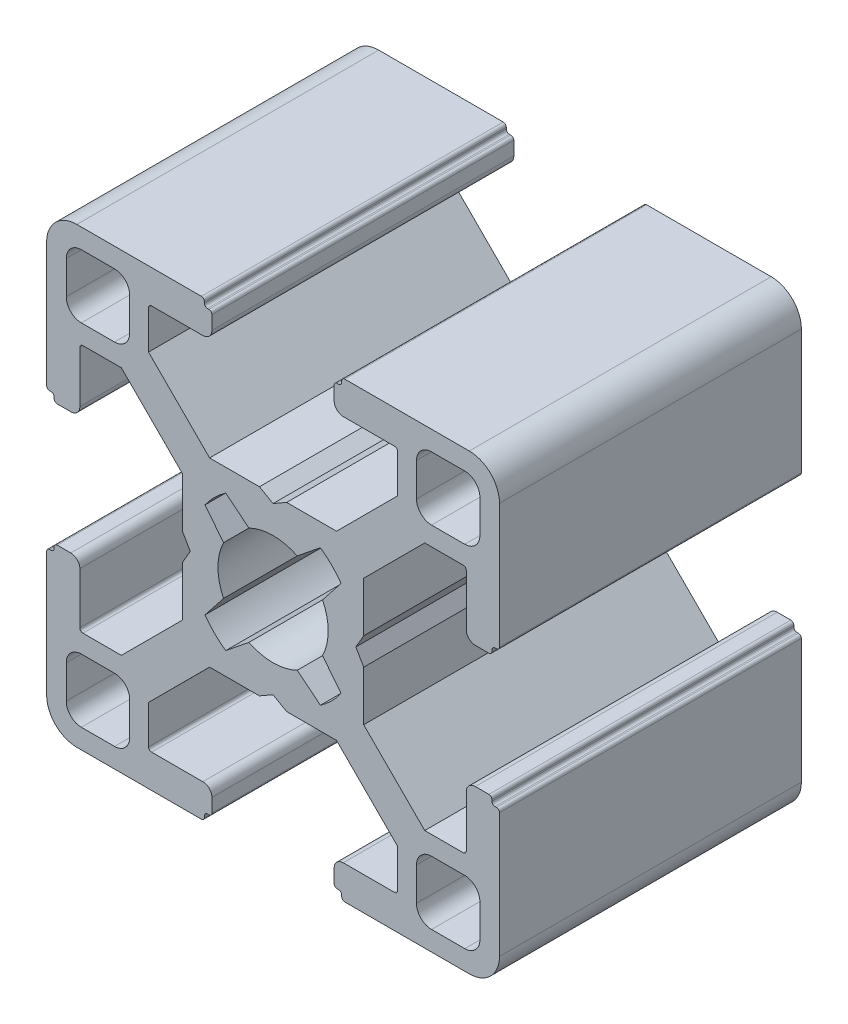
from build123d import *

# Parameters (mm, degrees)
DODANIE_WYCI_GNI_CIE1_DEPTH = 20


with BuildPart() as part:
    # Szkic1 → Dodanie-wyciągnięcie1 (new body)
    with BuildSketch(Plane.XY):
        with BuildLine():
            Line((96.56, 29.575148163), (97.459999946, 29.06))
            Line((97.459999946, 29.06), (100.764466193, 29.06))
            Line((100.764466193, 29.06), (104.810000327, 25.010000763))
            Line((104.810000327, 25.010000763), (104.810000327, 22.460001166))
            ThreePointArc((104.810000327, 22.460001166), (104.751421565, 22.318579525), (104.609999924, 22.260000763))
            Line((104.609999924, 22.260000763), (101.210000197, 22.260000763))
            ThreePointArc((101.210000197, 22.260000763), (100.785735989, 22.084264774), (100.61, 21.660000566))
            Line((100.61, 21.660000566), (100.61, 20.760000374))
            ThreePointArc((100.61, 20.760000374), (100.668578753, 20.618578753), (100.810000374, 20.56))
            Line((100.810000374, 20.56), (100.910000144, 20.56))
            ThreePointArc((100.910000144, 20.56), (101.05142109, 20.501421526), (101.109999564, 20.36000058))
            Line((101.109999564, 20.36000058), (101.109999564, 20.260000381))
            ThreePointArc((101.109999564, 20.260000381), (101.16857832, 20.118578755), (101.309999945, 20.06))
            Line((101.309999945, 20.06), (109.560000346, 20.06))
            ThreePointArc((109.560000346, 20.06), (110.974213664, 20.645786336), (111.56, 22.059999654))
            Line((111.56, 22.059999654), (111.56, 30.310000479))
            ThreePointArc((111.56, 30.310000479), (111.501421273, 30.451422036), (111.359999716, 30.510000763))
            Line((111.359999716, 30.510000763), (111.260000611, 30.510000763))
            ThreePointArc((111.260000611, 30.510000763), (111.118579054, 30.56857949), (111.060000327, 30.710001047))
            Line((111.060000327, 30.710001047), (111.060000327, 30.810000479))
            ThreePointArc((111.060000327, 30.810000479), (111.0014216, 30.951422036), (110.860000043, 31.010000763))
            Line((110.860000043, 31.010000763), (109.95999994, 31.010000763))
            ThreePointArc((109.95999994, 31.010000763), (109.535735606, 30.834264722), (109.359999564, 30.410000387))
            Line((109.359999564, 30.410000387), (109.359999564, 27.010000284))
            ThreePointArc((109.359999564, 27.010000284), (109.301420837, 26.868578727), (109.15999928, 26.81))
            Line((109.15999928, 26.81), (106.609999564, 26.81))
            Line((106.609999564, 26.81), (102.56446543, 30.855534134))
            Line((102.56446543, 30.855534134), (102.56446543, 34.160000381))
            Line((102.56446543, 34.160000381), (102.044852164, 35.06))
            Line((102.044852164, 35.06), (102.56446543, 35.959999619))
            Line((102.56446543, 35.959999619), (102.56446543, 39.264465866))
            Line((102.56446543, 39.264465866), (106.609999564, 43.31))
            Line((106.609999564, 43.31), (109.15999928, 43.31))
            ThreePointArc((109.15999928, 43.31), (109.301420837, 43.251421273), (109.359999564, 43.109999716))
            Line((109.359999564, 43.109999716), (109.359999564, 39.709999613))
            ThreePointArc((109.359999564, 39.709999613), (109.535735606, 39.285735278), (109.95999994, 39.109999237))
            Line((109.95999994, 39.109999237), (110.860000043, 39.109999237))
            ThreePointArc((110.860000043, 39.109999237), (111.0014216, 39.168577964), (111.060000327, 39.309999521))
            Line((111.060000327, 39.309999521), (111.060000327, 39.409998953))
            ThreePointArc((111.060000327, 39.409998953), (111.118579054, 39.55142051), (111.260000611, 39.609999237))
            Line((111.260000611, 39.609999237), (111.359999716, 39.609999237))
            ThreePointArc((111.359999716, 39.609999237), (111.501421273, 39.668577964), (111.56, 39.809999521))
            Line((111.56, 39.809999521), (111.56, 48.060000346))
            ThreePointArc((111.56, 48.060000346), (110.974213664, 49.474213664), (109.560000346, 50.06))
            Line((109.560000346, 50.06), (101.309999945, 50.06))
            ThreePointArc((101.309999945, 50.06), (101.16857832, 50.001421245), (101.109999564, 49.859999619))
            Line((101.109999564, 49.859999619), (101.109999564, 49.75999942))
            ThreePointArc((101.109999564, 49.75999942), (101.05142109, 49.618578474), (100.910000144, 49.56))
            Line((100.910000144, 49.56), (100.810000374, 49.56))
            ThreePointArc((100.810000374, 49.56), (100.668578753, 49.501421247), (100.61, 49.359999626))
            Line((100.61, 49.359999626), (100.61, 48.459999434))
            ThreePointArc((100.61, 48.459999434), (100.785735989, 48.035735226), (101.210000197, 47.859999237))
            Line((101.210000197, 47.859999237), (104.609999924, 47.859999237))
            ThreePointArc((104.609999924, 47.859999237), (104.751421565, 47.801420475), (104.810000327, 47.659998834))
            Line((104.810000327, 47.659998834), (104.810000327, 45.109999237))
            Line((104.810000327, 45.109999237), (100.764466193, 41.06))
            Line((100.764466193, 41.06), (97.459999946, 41.06))
            Line((97.459999946, 41.06), (96.56, 40.544851837))
            Line((96.56, 40.544851837), (95.660000054, 41.06))
            Line((95.660000054, 41.06), (92.355533807, 41.06))
            Line((92.355533807, 41.06), (88.309999673, 45.109999237))
            Line((88.309999673, 45.109999237), (88.309999673, 47.659998834))
            ThreePointArc((88.309999673, 47.659998834), (88.368578435, 47.801420475), (88.510000076, 47.859999237))
            Line((88.510000076, 47.859999237), (91.909999803, 47.859999237))
            ThreePointArc((91.909999803, 47.859999237), (92.334264011, 48.035735226), (92.51, 48.459999434))
            Line((92.51, 48.459999434), (92.51, 49.359999626))
            ThreePointArc((92.51, 49.359999626), (92.451421247, 49.501421247), (92.309999626, 49.56))
            Line((92.309999626, 49.56), (92.209999856, 49.56))
            ThreePointArc((92.209999856, 49.56), (92.06857891, 49.618578474), (92.010000436, 49.75999942))
            Line((92.010000436, 49.75999942), (92.010000436, 49.859999619))
            ThreePointArc((92.010000436, 49.859999619), (91.95142168, 50.001421245), (91.810000055, 50.06))
            Line((91.810000055, 50.06), (83.559999654, 50.06))
            ThreePointArc((83.559999654, 50.06), (82.145786336, 49.474213664), (81.56, 48.060000346))
            Line((81.56, 48.060000346), (81.56, 39.809999521))
            ThreePointArc((81.56, 39.809999521), (81.618578727, 39.668577964), (81.760000284, 39.609999237))
            Line((81.760000284, 39.609999237), (81.859999389, 39.609999237))
            ThreePointArc((81.859999389, 39.609999237), (82.001420946, 39.55142051), (82.059999673, 39.409998953))
            Line((82.059999673, 39.409998953), (82.059999673, 39.309999521))
            ThreePointArc((82.059999673, 39.309999521), (82.1185784, 39.168577964), (82.259999957, 39.109999237))
            Line((82.259999957, 39.109999237), (83.16000006, 39.109999237))
            ThreePointArc((83.16000006, 39.109999237), (83.584264394, 39.285735278), (83.760000436, 39.709999613))
            Line((83.760000436, 39.709999613), (83.760000436, 43.109999716))
            ThreePointArc((83.760000436, 43.109999716), (83.818579163, 43.251421273), (83.96000072, 43.31))
            Line((83.96000072, 43.31), (86.510000436, 43.31))
            Line((86.510000436, 43.31), (90.55553457, 39.264465866))
            Line((90.55553457, 39.264465866), (90.55553457, 35.959999619))
            Line((90.55553457, 35.959999619), (91.075147836, 35.06))
            Line((91.075147836, 35.06), (90.55553457, 34.160000381))
            Line((90.55553457, 34.160000381), (90.55553457, 30.855534134))
            Line((90.55553457, 30.855534134), (86.510000436, 26.81))
            Line((86.510000436, 26.81), (83.96000072, 26.81))
            ThreePointArc((83.96000072, 26.81), (83.818579163, 26.868578727), (83.760000436, 27.010000284))
            Line((83.760000436, 27.010000284), (83.760000436, 30.410000387))
            ThreePointArc((83.760000436, 30.410000387), (83.584264394, 30.834264722), (83.16000006, 31.010000763))
            Line((83.16000006, 31.010000763), (82.259999957, 31.010000763))
            ThreePointArc((82.259999957, 31.010000763), (82.1185784, 30.951422036), (82.059999673, 30.810000479))
            Line((82.059999673, 30.810000479), (82.059999673, 30.710001047))
            ThreePointArc((82.059999673, 30.710001047), (82.001420946, 30.56857949), (81.859999389, 30.510000763))
            Line((81.859999389, 30.510000763), (81.760000284, 30.510000763))
            ThreePointArc((81.760000284, 30.510000763), (81.618578727, 30.451422036), (81.56, 30.310000479))
            Line((81.56, 30.310000479), (81.56, 22.059999654))
            ThreePointArc((81.56, 22.059999654), (82.145786336, 20.645786336), (83.559999654, 20.06))
            Line((83.559999654, 20.06), (91.810000055, 20.06))
            ThreePointArc((91.810000055, 20.06), (91.95142168, 20.118578755), (92.010000436, 20.260000381))
            Line((92.010000436, 20.260000381), (92.010000436, 20.36000058))
            ThreePointArc((92.010000436, 20.36000058), (92.06857891, 20.501421526), (92.209999856, 20.56))
            Line((92.209999856, 20.56), (92.309999626, 20.56))
            ThreePointArc((92.309999626, 20.56), (92.451421247, 20.618578753), (92.51, 20.760000374))
            Line((92.51, 20.760000374), (92.51, 21.660000566))
            ThreePointArc((92.51, 21.660000566), (92.334264011, 22.084264774), (91.909999803, 22.260000763))
            Line((91.909999803, 22.260000763), (88.510000076, 22.260000763))
            ThreePointArc((88.510000076, 22.260000763), (88.368578435, 22.318579525), (88.309999673, 22.460001166))
            Line((88.309999673, 22.460001166), (88.309999673, 25.010000763))
            Line((88.309999673, 25.010000763), (92.355533807, 29.06))
            Line((92.355533807, 29.06), (95.660000054, 29.06))
            Line((95.660000054, 29.06), (96.56, 29.575148163))
        make_face()
        with BuildLine():
            Line((109.26000109, 48.760000398), (107.060000327, 48.760000398))
            ThreePointArc((107.060000327, 48.760000398), (106.352893543, 48.467107182), (106.060000327, 47.760000398))
            Line((106.060000327, 47.760000398), (106.060000327, 45.559999635))
            ThreePointArc((106.060000327, 45.559999635), (106.352893543, 44.852892851), (107.060000327, 44.559999635))
            Line((107.060000327, 44.559999635), (109.26000109, 44.559999635))
            ThreePointArc((109.26000109, 44.559999635), (109.967107874, 44.852892851), (110.26000109, 45.559999635))
            Line((110.26000109, 45.559999635), (110.26000109, 47.760000398))
            ThreePointArc((110.26000109, 47.760000398), (109.967107874, 48.467107182), (109.26000109, 48.760000398))
        make_face(mode=Mode.SUBTRACT)
        with BuildLine():
            Line((94.959870476, 38.340561767), (93.424070588, 39.578400903))
            ThreePointArc((93.424070588, 39.578400903), (92.678997741, 38.957155561), (92.054663108, 38.214669473))
            Line((92.054663108, 38.214669473), (93.279438268, 36.660129597))
            ThreePointArc((93.279438268, 36.660129597), (92.91, 35.06), (93.279438268, 33.459870403))
            Line((93.279438268, 33.459870403), (92.054663108, 31.905330527))
            ThreePointArc((92.054663108, 31.905330527), (92.678997741, 31.162844439), (93.424070588, 30.541599097))
            Line((93.424070588, 30.541599097), (94.959870476, 31.779438233))
            ThreePointArc((94.959870476, 31.779438233), (96.56, 31.41), (98.160129524, 31.779438233))
            Line((98.160129524, 31.779438233), (99.695929412, 30.541599097))
            ThreePointArc((99.695929412, 30.541599097), (100.441002259, 31.162844439), (101.065336892, 31.905330527))
            Line((101.065336892, 31.905330527), (99.840561732, 33.459870403))
            ThreePointArc((99.840561732, 33.459870403), (100.21, 35.06), (99.840561732, 36.660129597))
            Line((99.840561732, 36.660129597), (101.065336892, 38.214669473))
            ThreePointArc((101.065336892, 38.214669473), (100.441002259, 38.957155561), (99.695929412, 39.578400903))
            Line((99.695929412, 39.578400903), (98.160129524, 38.340561767))
            ThreePointArc((98.160129524, 38.340561767), (96.56, 38.71), (94.959870476, 38.340561767))
        make_face(mode=Mode.SUBTRACT)
        with BuildLine():
            Line((83.85999891, 21.359999602), (86.059999673, 21.359999602))
            ThreePointArc((86.059999673, 21.359999602), (86.767106457, 21.652892818), (87.059999673, 22.359999602))
            Line((87.059999673, 22.359999602), (87.059999673, 24.560000365))
            ThreePointArc((87.059999673, 24.560000365), (86.767106457, 25.267107149), (86.059999673, 25.560000365))
            Line((86.059999673, 25.560000365), (83.85999891, 25.560000365))
            ThreePointArc((83.85999891, 25.560000365), (83.152892126, 25.267107149), (82.85999891, 24.560000365))
            Line((82.85999891, 24.560000365), (82.85999891, 22.359999602))
            ThreePointArc((82.85999891, 22.359999602), (83.152892126, 21.652892818), (83.85999891, 21.359999602))
        make_face(mode=Mode.SUBTRACT)
        with BuildLine():
            Line((110.26000109, 22.359999602), (110.26000109, 24.560000365))
            ThreePointArc((110.26000109, 24.560000365), (109.967107874, 25.267107149), (109.26000109, 25.560000365))
            Line((109.26000109, 25.560000365), (107.060000327, 25.560000365))
            ThreePointArc((107.060000327, 25.560000365), (106.352893543, 25.267107149), (106.060000327, 24.560000365))
            Line((106.060000327, 24.560000365), (106.060000327, 22.359999602))
            ThreePointArc((106.060000327, 22.359999602), (106.352893543, 21.652892818), (107.060000327, 21.359999602))
            Line((107.060000327, 21.359999602), (109.26000109, 21.359999602))
            ThreePointArc((109.26000109, 21.359999602), (109.967107874, 21.652892818), (110.26000109, 22.359999602))
        make_face(mode=Mode.SUBTRACT)
        with BuildLine():
            Line((86.059999673, 48.760000398), (83.85999891, 48.760000398))
            ThreePointArc((83.85999891, 48.760000398), (83.152892126, 48.467107182), (82.85999891, 47.760000398))
            Line((82.85999891, 47.760000398), (82.85999891, 45.559999635))
            ThreePointArc((82.85999891, 45.559999635), (83.152892126, 44.852892851), (83.85999891, 44.559999635))
            Line((83.85999891, 44.559999635), (86.059999673, 44.559999635))
            ThreePointArc((86.059999673, 44.559999635), (86.767106457, 44.852892851), (87.059999673, 45.559999635))
            Line((87.059999673, 45.559999635), (87.059999673, 47.760000398))
            ThreePointArc((87.059999673, 47.760000398), (86.767106457, 48.467107182), (86.059999673, 48.760000398))
        make_face(mode=Mode.SUBTRACT)
    extrude(amount=DODANIE_WYCI_GNI_CIE1_DEPTH)


solid = part.part
